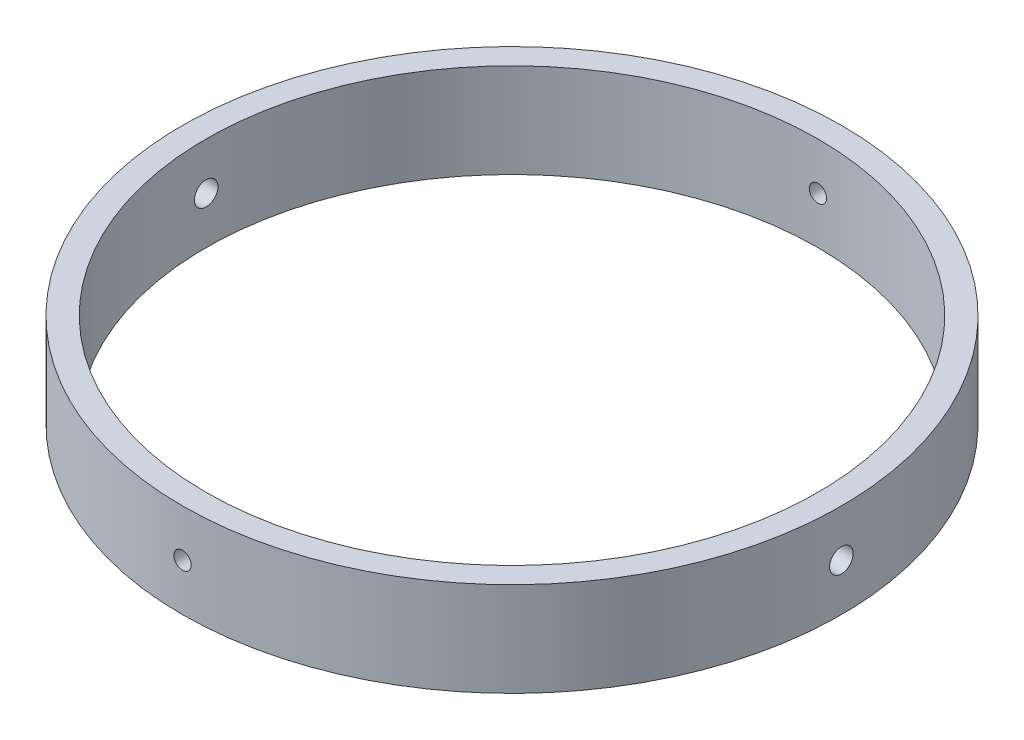
from build123d import *

# Parameters (mm, degrees)
SKETCH1_R               = 88.9
SKETCH1_R_2             = 82.55
BOSS_EXTRUDE1_DEPTH     = 25.4
SKETCH2_R               = 3.175
CUT_EXTRUDE1_DEPTH      = 89.9
CUT_EXTRUDE1_DEPTH_BACK = 89.9
SKETCH3_R               = 2.3368
CUT_EXTRUDE2_DEPTH      = 89.9000001
CUT_EXTRUDE2_DEPTH_BACK = 89.9000001


with BuildPart() as part:
    # Sketch1 → Boss-Extrude1 (new body)
    with BuildSketch(Plane(origin=(0, 0, 0), x_dir=(1, 0, 0), z_dir=(0, 1, 0))):
        Circle(SKETCH1_R)
        Circle(SKETCH1_R_2, mode=Mode.SUBTRACT)
    extrude(amount=BOSS_EXTRUDE1_DEPTH)

    # Sketch2 → Cut-Extrude1 (cut, two sides)
    with BuildSketch(Plane(origin=(0, 0, 0), x_dir=(0, 0, -1), z_dir=(1, 0, 0))) as cut_extrude1_sk:
        with Locations((0, 12.7)):
            Circle(SKETCH2_R)
    extrude(amount=CUT_EXTRUDE1_DEPTH, mode=Mode.SUBTRACT)
    extrude(cut_extrude1_sk.sketch, amount=-CUT_EXTRUDE1_DEPTH_BACK, mode=Mode.SUBTRACT)

    # Sketch3 → Cut-Extrude2 (cut, two sides)
    with BuildSketch(Plane.XY) as cut_extrude2_sk:
        with Locations((0, 12.7)):
            Circle(SKETCH3_R)
    extrude(amount=CUT_EXTRUDE2_DEPTH, mode=Mode.SUBTRACT)
    extrude(cut_extrude2_sk.sketch, amount=-CUT_EXTRUDE2_DEPTH_BACK, mode=Mode.SUBTRACT)


solid = part.part
